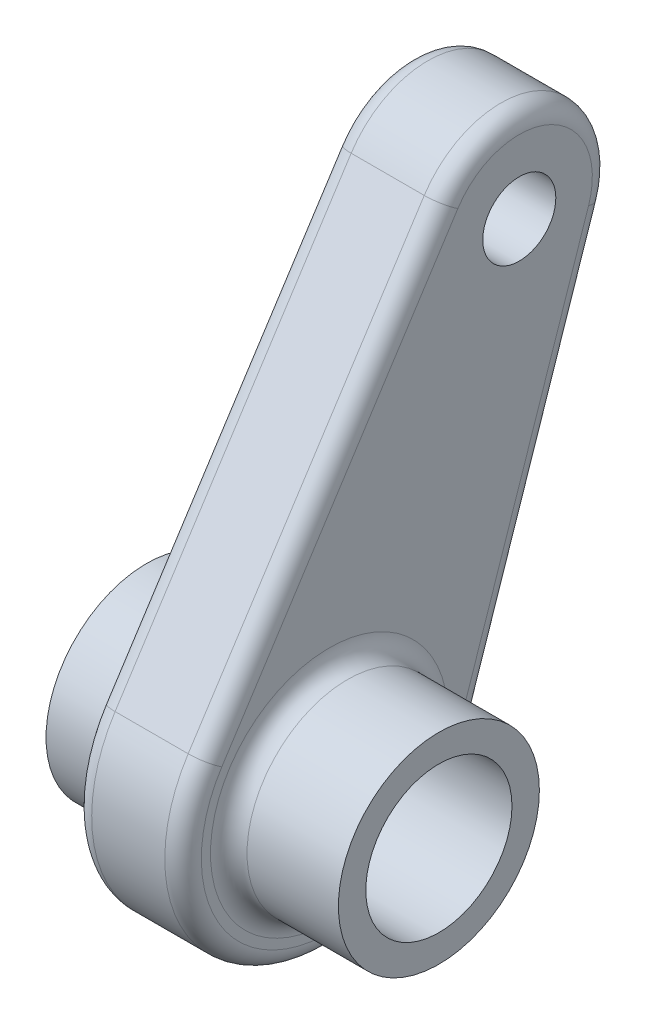
from build123d import *

# Parameters (mm, degrees)
SKETCH1_R           = 17.4625
SKETCH1_R_2         = 12.7
BOSS_EXTRUDE1_DEPTH = 12.7
BOSS_EXTRUDE2_START = 19.05
SKETCH1_3_R         = 6.35
SKETCH1_3_R_2       = 12.7
BOSS_EXTRUDE2_DEPTH = 19.05
BOSS_EXTRUDE3_START = 38.1
SKETCH1_4_R         = 17.4625
SKETCH1_4_R_2       = 12.7
BOSS_EXTRUDE3_DEPTH = 38.1
FILLET1_R           = 3.175


with BuildPart() as part:
    # Sketch1 → Boss-Extrude1 (new body)
    with BuildSketch(Plane(origin=(0, 0, 0), x_dir=(0, 0, -1), z_dir=(1, 0, 0))):
        Circle(SKETCH1_R)
        Circle(SKETCH1_R_2, mode=Mode.SUBTRACT)
    extrude(amount=-BOSS_EXTRUDE1_DEPTH)

    # Sketch1_3 → Boss-Extrude2 (add)
    with BuildSketch(Plane(origin=(0, 0, 0), x_dir=(0, 0, -1), z_dir=(1, 0, 0)).offset(BOSS_EXTRUDE2_START)):
        with BuildLine():
            Line((24.088040055, -8.057687403), (48.071506693, 63.6396466))
            ThreePointArc((48.071506693, 63.6396466), (39.894915337, 82.983138982), (19.681065043, 77.288615292))
            Line((19.681065043, 77.288615292), (-21.336666584, 13.780662505))
            ThreePointArc((-21.336666584, 13.780662505), (-11.005493886, -22.891900409), (24.088040055, -8.057687403))
        make_face()
        with Locations((33.016481658, 68.675701226)):
            Circle(SKETCH1_3_R, mode=Mode.SUBTRACT)
        Circle(SKETCH1_3_R_2, mode=Mode.SUBTRACT)
    extrude(amount=-BOSS_EXTRUDE2_DEPTH)

    # Sketch1_4 → Boss-Extrude3 (add)
    with BuildSketch(Plane(origin=(0, 0, 0), x_dir=(0, 0, -1), z_dir=(1, 0, 0)).offset(BOSS_EXTRUDE3_START)):
        Circle(SKETCH1_4_R)
        Circle(SKETCH1_4_R_2, mode=Mode.SUBTRACT)
    extrude(amount=-BOSS_EXTRUDE3_DEPTH)

    # Fillet1
    fillet1_edges = [part.edges().sort_by_distance(p)[0] for p in [
        (0, 45.534638899, 0.827800771),
        (0, 82.983138982, -39.894915337),
        (0, 27.790979598, -36.079773374),
        (19.05, 45.534638899, 0.827800771),
        (19.05, 82.983138982, -39.894915337),
        (19.05, 27.790979598, -36.079773374),
        (0, 0, 17.4625),
        (0, -22.891900409, 11.005493886),
        (19.05, -22.891900409, 11.005493886),
        (19.05, 0, 17.4625),
    ]]
    fillet(fillet1_edges, radius=FILLET1_R)


solid = part.part
